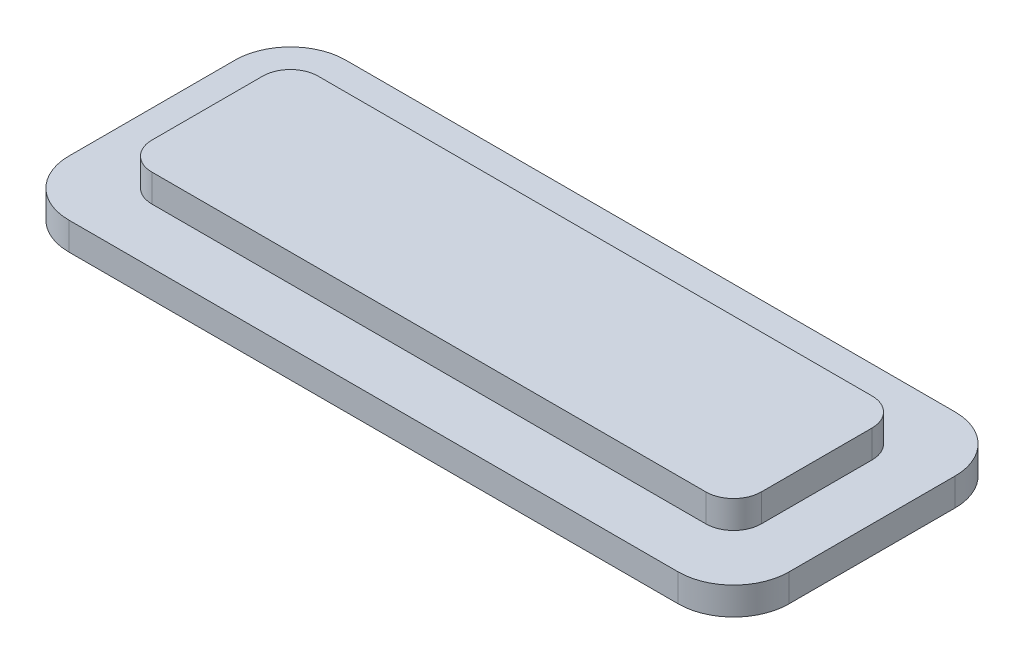
from build123d import *

# Parameters (mm, degrees)
SKETCH1_W           = 22
SKETCH1_H           = 6
BOSS_EXTRUDE1_DEPTH = 1
BOSS_EXTRUDE2_DEPTH = 1
FILLET1_R           = 1


with BuildPart() as part:
    # Sketch1 → Boss-Extrude1 (new body)
    with BuildSketch(Plane(origin=(0, 0, 0), x_dir=(1, 0, 0), z_dir=(0, 1, 0))):
        Rectangle(SKETCH1_W, SKETCH1_H)
    extrude(amount=BOSS_EXTRUDE1_DEPTH)

    # Sketch2 → Boss-Extrude2 (add)
    with BuildSketch(Plane.XZ):
        with BuildLine():
            Line((11, 5), (-11, 5))
            ThreePointArc((-11, 5), (-12.414213562, 4.414213562), (-13, 3))
            Line((-13, 3), (-13, -3))
            ThreePointArc((-13, -3), (-12.414213562, -4.414213562), (-11, -5))
            Line((-11, -5), (11, -5))
            ThreePointArc((11, -5), (12.414213562, -4.414213562), (13, -3))
            Line((13, -3), (13, 3))
            ThreePointArc((13, 3), (12.414213562, 4.414213562), (11, 5))
        make_face()
    extrude(amount=BOSS_EXTRUDE2_DEPTH)

    # Fillet1
    fillet1_edges = [part.edges().sort_by_distance(p)[0] for p in [
        (11, 0.5, 3),
        (11, 0.5, -3),
        (-11, 0.5, -3),
        (-11, 0.5, 3),
    ]]
    fillet(fillet1_edges, radius=FILLET1_R)


solid = part.part
